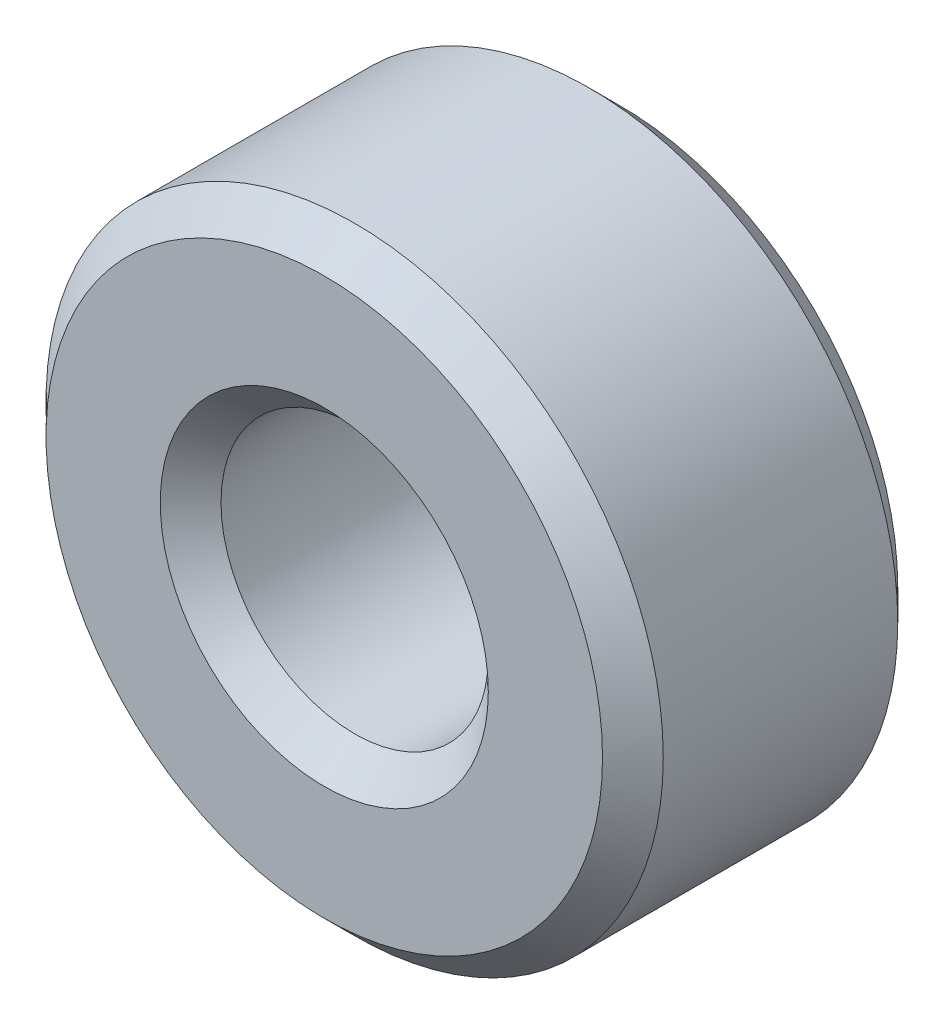
from build123d import *

# Parameters (mm, degrees)
ESBO_O1_R                = 25.4
ESBO_O1_R_2              = 11
RESSALTO_EXTRUS_O1_DEPTH = 24.3
CHANFRO1_SIZE            = 2.5


with BuildPart() as part:
    # Esboço1 → Ressalto-extrusão1 (new body)
    with BuildSketch(Plane.XY):
        Circle(ESBO_O1_R)
        Circle(ESBO_O1_R_2, mode=Mode.SUBTRACT)
    extrude(amount=RESSALTO_EXTRUS_O1_DEPTH)

    # Chanfro1
    chanfro1_edges = [part.edges().sort_by_distance(p)[0] for p in [
        (-25.4, 0, 0),
        (-25.4, 0, 24.3),
        (-11, 0, 0),
        (-11, 0, 24.3),
    ]]
    chamfer(chanfro1_edges, length=CHANFRO1_SIZE)


solid = part.part
